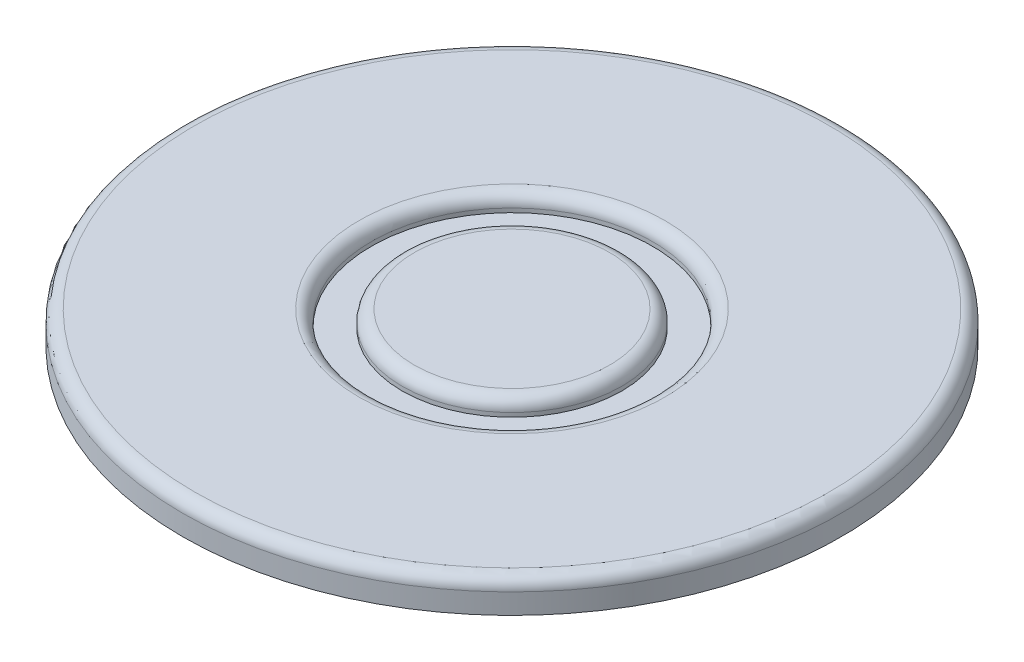
from build123d import *

# Parameters (mm, degrees)
CROQUIS1_R              = 45
CROQUIS1_R_2            = 40.5
CROQUIS1_R_3            = 17.3
CROQUIS1_R_4            = 13.5
SALIENTE_EXTRUIR1_DEPTH = 2
CROQUIS2_R              = 45
SALIENTE_EXTRUIR2_DEPTH = 2
CROQUIS3_R              = 56.484635106
CROQUIS3_R_2            = 40.5
CORTAR_EXTRUIR1_DEPTH   = 10
REDONDEO2_R             = 1.5


with BuildPart() as part:
    # Croquis1 → Saliente-Extruir1 (new body)
    with BuildSketch(Plane(origin=(0, 0, 0), x_dir=(1, 0, 0), z_dir=(0, 1, 0))):
        Circle(CROQUIS1_R)
        Circle(CROQUIS1_R_2, mode=Mode.SUBTRACT)
        Circle(CROQUIS1_R_2)
        Circle(CROQUIS1_R_3, mode=Mode.SUBTRACT)
        Circle(CROQUIS1_R_4)
    extrude(amount=SALIENTE_EXTRUIR1_DEPTH)

    # Croquis2 → Saliente-Extruir2 (add)
    with BuildSketch(Plane.XZ):
        Circle(CROQUIS2_R)
    extrude(amount=SALIENTE_EXTRUIR2_DEPTH)

    # Croquis3 → Cortar-Extruir1 (cut)
    with BuildSketch(Plane(origin=(0, 2, 0), x_dir=(1, 0, 0), z_dir=(0, 1, 0))):
        Circle(CROQUIS3_R)
        Circle(CROQUIS3_R_2, mode=Mode.SUBTRACT)
    extrude(amount=-CORTAR_EXTRUIR1_DEPTH, mode=Mode.SUBTRACT)

    # Redondeo2
    redondeo2_edges = [part.edges().sort_by_distance(p)[0] for p in [
        (-13.5, 2, 0),
        (-40.5, 2, 0),
        (-17.3, 2, 0),
    ]]
    fillet(redondeo2_edges, radius=REDONDEO2_R)


solid = part.part
